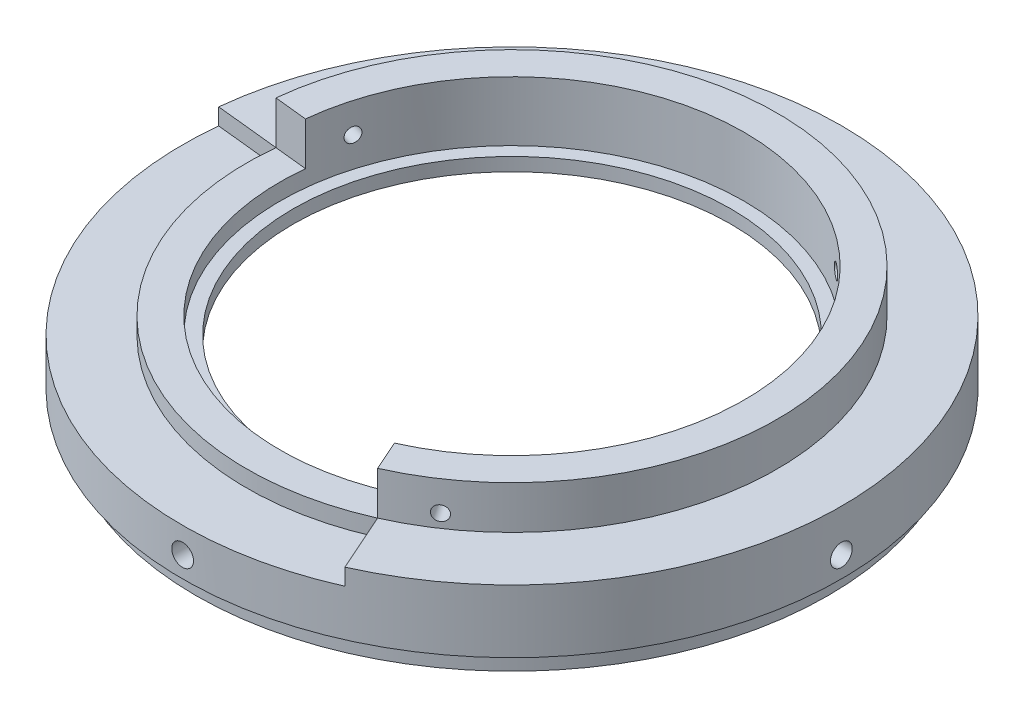
from build123d import *

# Parameters (mm, degrees)
SKETCH5_R          = 1.6425
CUT_EXTRUDE1_DEPTH = 50.7
SKETCH6_R          = 1.095
CUT_EXTRUDE2_DEPTH = 70.421071799
CIRPATTERN1_COUNT  = 4
CUT_EXTRUDE3_DEPTH = 6.5
CUT_EXTRUDE4_DEPTH = 2.5
CIRPATTERN2_COUNT  = 2
CIRPATTERN2_ANGLE  = 110
CIRPATTERN3_COUNT  = 2
CIRPATTERN3_ANGLE  = 110


with BuildPart() as part:
    # Sketch2 → Revolve1 (revolve)
    with BuildSketch(Plane.XY, mode=Mode.PRIVATE) as revolve1_sk:
        Polygon((49.7, 12.7), (49.7, 3.2004), (47.675, 3.2004), (47.675, 0), (44.7, 0), (33, 8.2), (33, 10.2), (35, 10.2), (35, 19.2), (40, 19.2), (40, 12.7), align=None)
    revolve(revolve1_sk.sketch.rotate(Axis((0, 0, 0), (0, 1, 0)), 90), axis=Axis((0, 0, 0), (0, 1, 0)))  # turned: the seam where the file's is

    # Sketch5 → Cut-Extrude1 (cut, through all)
    with BuildSketch(Plane.XY):
        with Locations(Location((0, 6.35, 0), (0, 0, 89.999999357))):  # turned: the seam where the file's is
            Circle(SKETCH5_R)
    cut_extrude1 = extrude(amount=-CUT_EXTRUDE1_DEPTH, mode=Mode.SUBTRACT)

    # Sketch6 → Cut-Extrude2 (cut, through all)
    with BuildSketch(Plane(origin=(0, 0, 0), x_dir=(0.809016994, 0, 0.587785252), z_dir=(-0.587785252, 0, 0.809016994))):
        with Locations((0, 14.7)):
            Circle(SKETCH6_R)
    cut_extrude2 = extrude(amount=-CUT_EXTRUDE2_DEPTH, mode=Mode.SUBTRACT)

    # CirPattern1: Cut-Extrude1 ×4 about axis
    cirpattern1_axis = Axis((0, 13.335, 0), (0, -1, 0))
    for i in range(1, CIRPATTERN1_COUNT):
        add(cut_extrude1.rotate(cirpattern1_axis, i * 360 / CIRPATTERN1_COUNT), mode=Mode.SUBTRACT)

    # Sketch7 → Cut-Extrude3 (cut)
    with BuildSketch(Plane(origin=(0, 19.2, 0), x_dir=(-1, 0, 0), z_dir=(0, 1, 0))):
        with BuildLine():
            Line((39.780875815, -4.181138531), (34.808266338, -3.658496214))
            ThreePointArc((34.808266338, -3.658496214), (20.57248383, 28.315594803), (-14.235782508, 31.974091017))
            Line((-14.235782508, 31.974091017), (-16.269465723, 36.541818306))
            ThreePointArc((-16.269465723, 36.541818306), (23.511410092, 32.360679775), (39.780875815, -4.181138531))
        make_face()
    extrude(amount=-CUT_EXTRUDE3_DEPTH, mode=Mode.SUBTRACT)

    # Sketch8 → Cut-Extrude4 (cut)
    with BuildSketch(Plane(origin=(0, 12.7, 0), x_dir=(1, 0, 0), z_dir=(0, 1, 0))):
        with BuildLine():
            Line((-49.4277382, 5.195064624), (-39.780875815, 4.181138531))
            ThreePointArc((-39.780875815, 4.181138531), (-23.511410092, -32.360679775), (16.269465723, -36.541818306))
            Line((16.269465723, -36.541818306), (20.214811161, -45.403209245))
            ThreePointArc((20.214811161, -45.403209245), (-29.212927039, -40.20814462), (-49.4277382, 5.195064624))
        make_face()
    extrude(amount=-CUT_EXTRUDE4_DEPTH, mode=Mode.SUBTRACT)

    # CirPattern2: Cut-Extrude2 ×2 about axis
    cirpattern2_axis = Axis((0, 13.335, 0), (0, -1, 0))
    for i in range(1, CIRPATTERN2_COUNT):
        add(cut_extrude2.rotate(cirpattern2_axis, i * CIRPATTERN2_ANGLE / (CIRPATTERN2_COUNT - 1)), mode=Mode.SUBTRACT)

    # CirPattern3: Cut-Extrude2 ×2 about axis
    cirpattern3_axis = Axis((0, 13.335, 0), (0, 1, 0))
    for i in range(1, CIRPATTERN3_COUNT):
        add(cut_extrude2.rotate(cirpattern3_axis, i * CIRPATTERN3_ANGLE / (CIRPATTERN3_COUNT - 1)), mode=Mode.SUBTRACT)


solid = part.part
